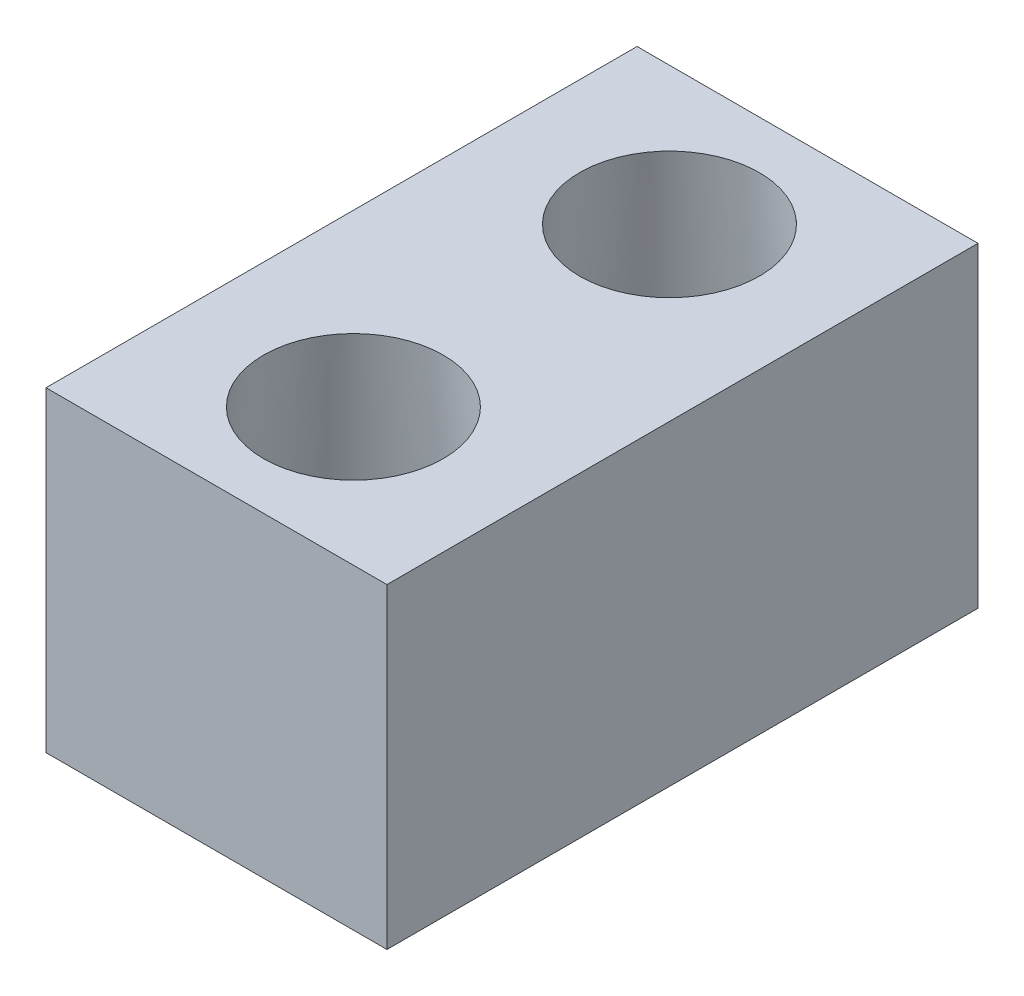
from build123d import *

# Parameters (mm, degrees)
SKETCH2_W           = 54.8
SKETCH2_H           = 95
BOSS_EXTRUDE1_DEPTH = 50.8
SKETCH3_R           = 19.05
CUT_EXTRUDE1_DEPTH  = 5
SKETCH4_R           = 14.435817204
SKETCH4_166_R       = 14.435817204


with BuildPart() as part:
    # Sketch2 → Boss-Extrude1 (new body)
    with BuildSketch(Plane(origin=(0, 0, 0), x_dir=(1, 0, 0), z_dir=(0, 1, 0))):
        with Locations((0, -0.795454545)):
            Rectangle(SKETCH2_W, SKETCH2_H)
    extrude(amount=BOSS_EXTRUDE1_DEPTH)

    # Sketch3 → Cut-Extrude1 (cut)
    with BuildSketch(Plane.XZ):
        with Locations(Location((-0.029477, 26.254895545, 0), (0, 0, 270))):
            Circle(SKETCH3_R)
        with Locations(Location((-0.029477, -24.545104455, 0), (0, 0, 90))):
            Circle(SKETCH3_R)
    extrude(amount=-CUT_EXTRUDE1_DEPTH, mode=Mode.SUBTRACT)

    # Sketch4 → section 0 of cut_loft1
    with BuildSketch(Plane(origin=(0, 50.8, 0), x_dir=(1, 0, 0), z_dir=(0, 1, 0)), mode=Mode.PRIVATE) as cut_loft1_s0:
        with Locations((-0.029477, 24.545104455)):
            Circle(SKETCH4_R)
    # loft up to a face of the part (cut_loft1)
    loft([cut_loft1_s0.sketch, Face(Wire([part.edges().sort_by_distance((-13.916329352, 5, -37.585726822))[0]]))], mode=Mode.SUBTRACT)

    # Sketch4_166 → section 0 of cut_loft2
    with BuildSketch(Plane(origin=(0, 50.8, 0), x_dir=(1, 0, 0), z_dir=(0, 1, 0)), mode=Mode.PRIVATE) as cut_loft2_s0:
        with Locations((-0.029477, -26.254895545)):
            Circle(SKETCH4_166_R)
    # loft up to a face of the part (cut_loft2)
    loft([cut_loft2_s0.sketch, Face(Wire([part.edges().sort_by_distance((13.857375352, 5, 39.295517913))[0]]))], mode=Mode.SUBTRACT)


solid = part.part
